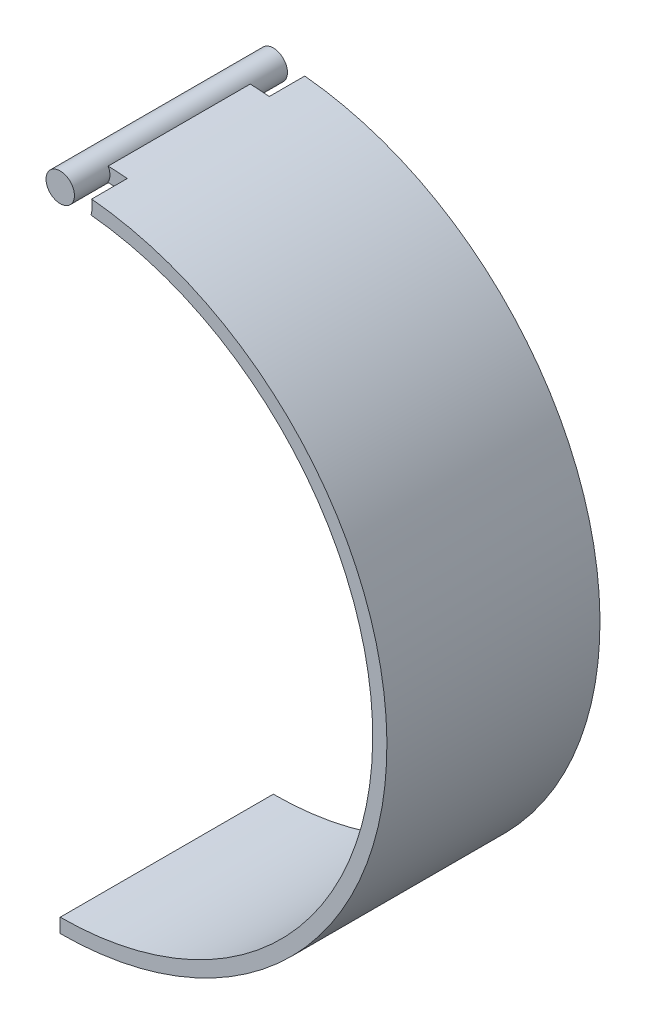
from build123d import *

# Parameters (mm, degrees)
SKETCH_1_R          = 1
EXTRUDE_1_DEPTH     = 15
EXTRUDE_2_DEPTH     = 15
CUT_EXTRUDE_1_DEPTH = 2.5
CUT_EXTRUDE_2_DEPTH = 2.5


with BuildPart() as part:
    # ｽｹｯﾁ1 → ﾎﾞｽ - 押し出し1 (new body)
    with BuildSketch(Plane.XY):
        Circle(SKETCH_1_R)
    extrude(amount=EXTRUDE_1_DEPTH)

    # ｽｹｯﾁ2 → ﾎﾞｽ - 押し出し2 (add)
    with BuildSketch(Plane.XY.offset(15)):
        with BuildLine():
            Line((0, -44.5), (0, -45.5))
            ThreePointArc((0, -45.5), (23, -22.5), (0, 0.5))
            Line((0, 0.5), (0, -0.5))
            ThreePointArc((0, -0.5), (22, -22.5), (0, -44.5))
        make_face()
    extrude(amount=-EXTRUDE_2_DEPTH)

    # ｽｹｯﾁ3 → ｶｯﾄ - 押し出し1 (cut)
    with BuildSketch(Plane.XY.offset(15)):
        with BuildLine():
            ThreePointArc((0.875436399, 0.483333333), (0.999814775, -0.019246198), (0.856186636, -0.516666667))
            ThreePointArc((0.856186636, -0.516666667), (1.51206294, -0.552023654), (2.166591434, -0.606944444))
            ThreePointArc((2.166591434, -0.606944444), (2.247324467, -0.109693843), (2.215402295, 0.393055556))
            ThreePointArc((2.215402295, 0.393055556), (1.546078419, 0.44797685), (0.875436399, 0.483333333))
        make_face()
    extrude(amount=-CUT_EXTRUDE_1_DEPTH, mode=Mode.SUBTRACT)

    # ｽｹｯﾁ4 → ｶｯﾄ - 押し出し2 (cut)
    with BuildSketch(Plane(origin=(0, 0, 0), x_dir=(-1, 0, 0), z_dir=(0, 0, -1))):
        with BuildLine():
            ThreePointArc((-0.875436399, 0.483333333), (-0.999814775, -0.019246198), (-0.856186636, -0.516666667))
            ThreePointArc((-0.856186636, -0.516666667), (-1.51206294, -0.552023654), (-2.166591434, -0.606944444))
            ThreePointArc((-2.166591434, -0.606944444), (-2.247324467, -0.109693843), (-2.215402295, 0.393055556))
            ThreePointArc((-2.215402295, 0.393055556), (-1.546078419, 0.44797685), (-0.875436399, 0.483333333))
        make_face()
    extrude(amount=-CUT_EXTRUDE_2_DEPTH, mode=Mode.SUBTRACT)


solid = part.part
